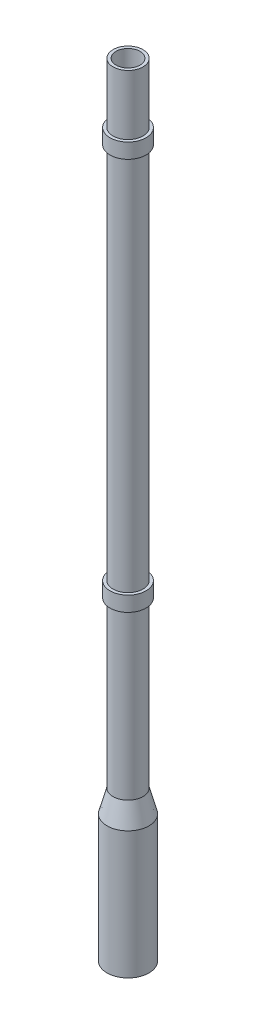
from build123d import *

# Parameters (mm, degrees)
SKETCH3_R           = 60
SKETCH3_R_2         = 40
BOSS_EXTRUDE1_DEPTH = 50
SKETCH4_R           = 60
SKETCH4_R_2         = 40
BOSS_EXTRUDE3_DEPTH = 50


with BuildPart() as part:
    # Sketch1 → Revolve1 (revolve)
    with BuildSketch(Plane.XY):
        Polygon((-70, -74.641016151), (-70, -500), (-60, -500), (-60, -75.957541127), (-40, -1.316524976), (-40, 2110), (-50, 2110), (-50, 0), align=None)
    revolve(axis=Axis((0, 0, 0), (0, 1, 0)))

    # Sketch3 → Boss-Extrude1 (add)
    with BuildSketch(Plane(origin=(0, 1860, 0), x_dir=(1, 0, 0), z_dir=(0, 1, 0))):
        Circle(SKETCH3_R)
        Circle(SKETCH3_R_2, mode=Mode.SUBTRACT)
    extrude(amount=BOSS_EXTRUDE1_DEPTH)

    # Sketch4 → Boss-Extrude3 (add)
    with BuildSketch(Plane(origin=(0, 600, 0), x_dir=(1, 0, 0), z_dir=(0, 1, 0))):
        Circle(SKETCH4_R)
        Circle(SKETCH4_R_2, mode=Mode.SUBTRACT)
    extrude(amount=-BOSS_EXTRUDE3_DEPTH)


solid = part.part
